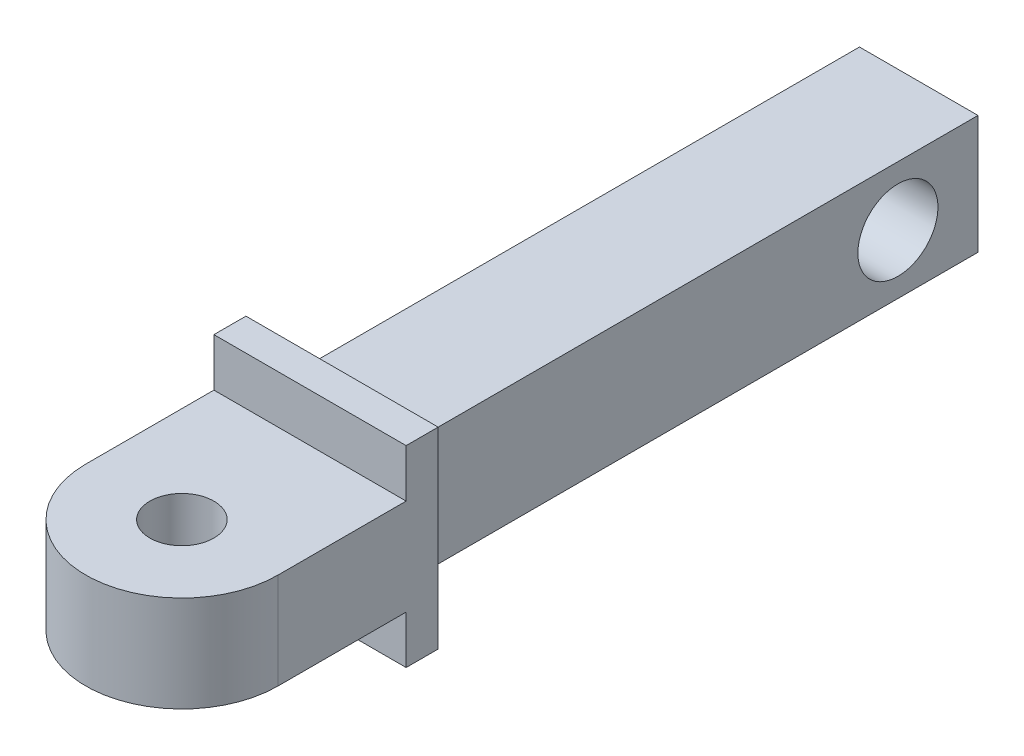
from build123d import *

# Parameters (mm, degrees)
SKETCH_1_W           = 6
SKETCH_1_H           = 6
EXTRUDE_1_DEPTH      = 1
SKETCH_2_R           = 1
EXTRUDE_2_DEPTH      = 1.5
EXTRUDE_2_DEPTH_BACK = 1.5
SKETCH_3_W           = 3.7
SKETCH_3_H           = 3.7
EXTRUDE_3_DEPTH      = 18
SKETCH_4_R           = 1.25
CUT_EXTRUDE_1_DEPTH  = 3.7


with BuildPart() as part:
    # 스케치1 → 보스-돌출1 (new body)
    with BuildSketch(Plane.XY):
        Rectangle(SKETCH_1_W, SKETCH_1_H)
    extrude(amount=EXTRUDE_1_DEPTH)

    # 스케치2 → 보스-돌출2 (add, two sides)
    with BuildSketch(Plane(origin=(0, 0, 0), x_dir=(1, 0, 0), z_dir=(0, 1, 0))) as extrude_2_sk:
        with BuildLine():
            Line((-3, -1), (3, -1))
            Line((3, -1), (3, -5))
            ThreePointArc((3, -5), (0, -8), (-3, -5))
            Line((-3, -5), (-3, -1))
        make_face()
        with Locations((0, -5)):
            Circle(SKETCH_2_R, mode=Mode.SUBTRACT)
    extrude(amount=EXTRUDE_2_DEPTH)
    extrude(extrude_2_sk.sketch, amount=-EXTRUDE_2_DEPTH_BACK)

    # 스케치3 → 보스-돌출3 (add)
    with BuildSketch(Plane(origin=(0, 0, 0), x_dir=(-1, 0, 0), z_dir=(0, 0, -1))):
        Rectangle(SKETCH_3_W, SKETCH_3_H)
    extrude(amount=EXTRUDE_3_DEPTH)

    # 스케치4 → 컷-돌출1 (cut)
    with BuildSketch(Plane.ZY.offset(1.85)):
        with Locations((-15.5, 0)):
            Circle(SKETCH_4_R)
    extrude(amount=-CUT_EXTRUDE_1_DEPTH, mode=Mode.SUBTRACT)


solid = part.part
